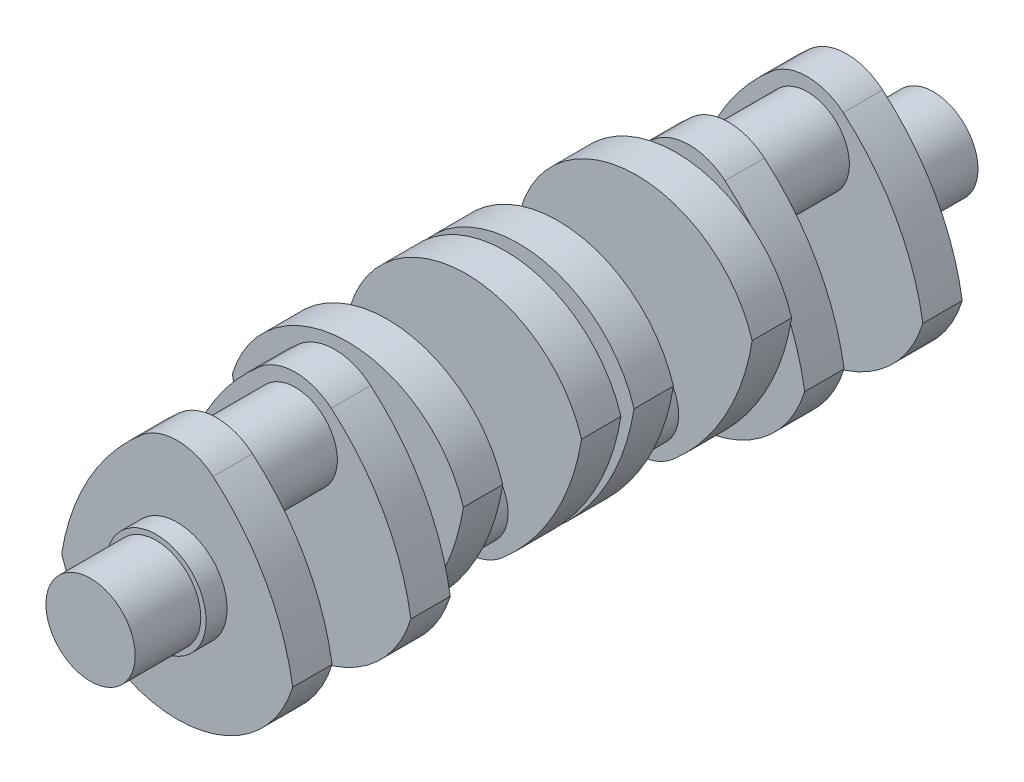
from build123d import *

# Parameters (mm, degrees)
SKETCH1_R            = 17
BOSS_EXTRUDE2_DEPTH  = 25
SKETCH1_7_R          = 19
BOSS_EXTRUDE4_DEPTH  = 8
BOSS_EXTRUDE5_DEPTH  = 15
SKETCH5_R            = 16
BOSS_EXTRUDE6_DEPTH  = 15
SKETCH6_R            = 17
BOSS_EXTRUDE7_DEPTH  = 5
BOSS_EXTRUDE8_DEPTH  = 15
SKETCH8_R            = 16
BOSS_EXTRUDE9_DEPTH  = 30
BOSS_EXTRUDE10_DEPTH = 15
SKETCH10_R           = 17
BOSS_EXTRUDE13_DEPTH = 2.5


with BuildPart() as part:
    # Sketch1 → Boss-Extrude2 (new body)
    with BuildSketch(Plane.XY):
        Circle(SKETCH1_R)
    extrude(amount=-BOSS_EXTRUDE2_DEPTH)

    # Sketch1_7 → Boss-Extrude4 (add)
    with BuildSketch(Plane.XY):
        Circle(SKETCH1_7_R)
    extrude(amount=BOSS_EXTRUDE4_DEPTH)

    # Sketch4 → Boss-Extrude5 (add)
    with BuildSketch(Plane.XY.offset(8)):
        with BuildLine():
            ThreePointArc((-13.668094758, 40.943123461), (0, 46), (13.668094758, 40.943123461))
            ThreePointArc((13.668094758, 40.943123461), (33.683444249, 16.469257624), (44, -13.416407865))
            ThreePointArc((44, -13.416407865), (0, -46), (-44, -13.416407865))
            ThreePointArc((-44, -13.416407865), (-33.683444249, 16.469257624), (-13.668094758, 40.943123461))
        make_face()
    boss_extrude5 = extrude(amount=BOSS_EXTRUDE5_DEPTH)

    # Sketch5 → Boss-Extrude6 (add)
    with BuildSketch(Plane.XY.offset(23)):
        with Locations((0, 25)):
            Circle(SKETCH5_R)
    boss_extrude6 = extrude(amount=BOSS_EXTRUDE6_DEPTH)

    # Mirror2: Boss-Extrude5, Boss-Extrude6 across plane
    add(boss_extrude5.mirror(Plane(origin=(0, 25, 38), x_dir=(1, 0, 0), z_dir=(0, 0, 1))))
    add(boss_extrude6.mirror(Plane(origin=(0, 25, 38), x_dir=(1, 0, 0), z_dir=(0, 0, 1))))

    # Sketch6 → Boss-Extrude7 (add)
    with BuildSketch(Plane.XY.offset(68)):
        Circle(SKETCH6_R)
    extrude(amount=BOSS_EXTRUDE7_DEPTH)

    # Sketch7 → Boss-Extrude8 (add)
    with BuildSketch(Plane.XY.offset(73)):
        with BuildLine():
            ThreePointArc((-13.668094758, -40.943123461), (0, -46), (13.668094758, -40.943123461))
            ThreePointArc((13.668094758, -40.943123461), (33.683444249, -16.469257624), (44, 13.416407865))
            ThreePointArc((44, 13.416407865), (0, 46), (-44, 13.416407865))
            ThreePointArc((-44, 13.416407865), (-33.683444249, -16.469257624), (-13.668094758, -40.943123461))
        make_face()
    extrude(amount=BOSS_EXTRUDE8_DEPTH)

    # Sketch8 → Boss-Extrude9 (add)
    with BuildSketch(Plane.XY.offset(88)):
        with Locations((0, -25)):
            Circle(SKETCH8_R)
    extrude(amount=BOSS_EXTRUDE9_DEPTH)

    # Sketch9 → Boss-Extrude10 (add)
    with BuildSketch(Plane.XY.offset(118)):
        with BuildLine():
            ThreePointArc((-13.668094758, -40.943123461), (0, -46), (13.668094758, -40.943123461))
            ThreePointArc((13.668094758, -40.943123461), (33.683444249, -16.469257624), (44, 13.416407865))
            ThreePointArc((44, 13.416407865), (0, 46), (-44, 13.416407865))
            ThreePointArc((-44, 13.416407865), (-33.683444249, -16.469257624), (-13.668094758, -40.943123461))
        make_face()
    extrude(amount=BOSS_EXTRUDE10_DEPTH)

    # Sketch10 → Boss-Extrude13 (add)
    with BuildSketch(Plane.XY.offset(133)):
        Circle(SKETCH10_R)
    extrude(amount=BOSS_EXTRUDE13_DEPTH)

    # Mirror9: part across plane


with BuildPart() as part_1:
    add(part.part)
    add(part.part.mirror(Plane.XY.offset(135.5)))


solid = part_1.part
